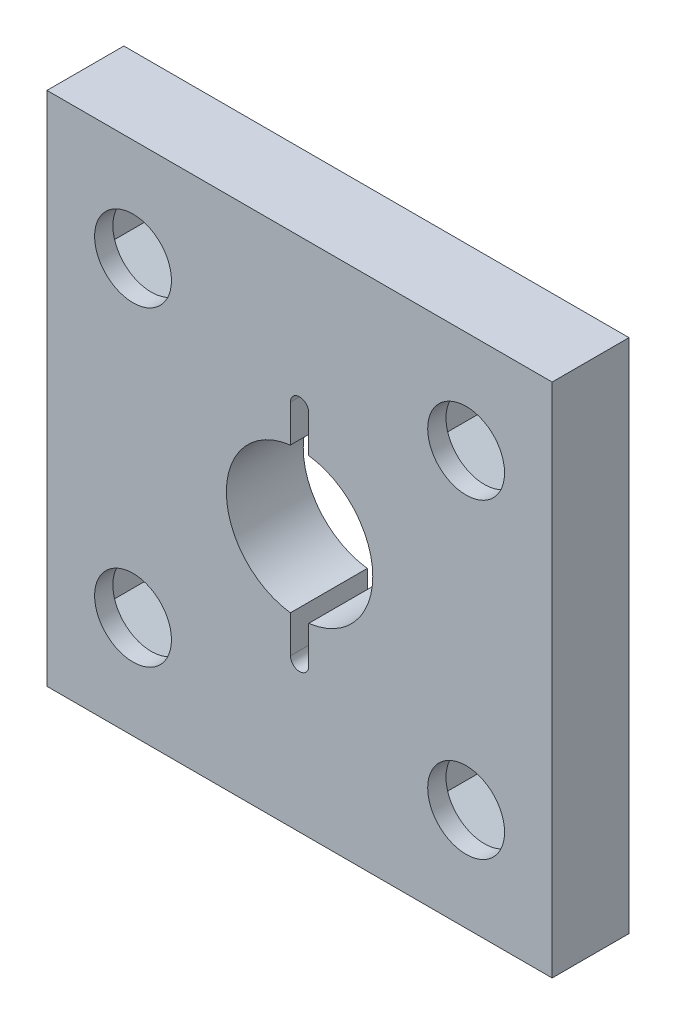
from build123d import *

# Parameters (mm, degrees)
SKETCH1_W           = 35.052
SKETCH1_H           = 35.814
SKETCH1_R           = 2.667
BOSS_EXTRUDE1_DEPTH = 5.334
CUT_EXTRUDE1_DEPTH  = 4.064
SKETCH3_R           = 5.08
CUT_EXTRUDE2_DEPTH  = 6.334
CUT_EXTRUDE3_DEPTH  = 6.334


with BuildPart() as part:
    # Sketch1 → Boss-Extrude1 (new body)
    with BuildSketch(Plane.XY):
        Rectangle(SKETCH1_W, SKETCH1_H)
        with Locations((-11.557, 10.795)):
            Circle(SKETCH1_R, mode=Mode.SUBTRACT)
        with Locations((11.557, 10.795)):
            Circle(SKETCH1_R, mode=Mode.SUBTRACT)
        with Locations((11.557, -10.795)):
            Circle(SKETCH1_R, mode=Mode.SUBTRACT)
        with Locations((-11.557, -10.795)):
            Circle(SKETCH1_R, mode=Mode.SUBTRACT)
    extrude(amount=BOSS_EXTRUDE1_DEPTH)

    # Sketch2 → Cut-Extrude1 (cut)
    with BuildSketch(Plane(origin=(0, 0, 0), x_dir=(-1, 0, 0), z_dir=(0, 0, -1))):
        Polygon((-11.557, 5.955650044), (-7.366, 8.375325022), (-7.366, 13.214674978), (-11.557, 15.634349956), (-15.748, 13.214674978), (-15.748, 8.375325022), align=None)
        Polygon((-11.557, -15.634349956), (-7.366, -13.214674978), (-7.366, -8.375325022), (-11.557, -5.955650044), (-15.748, -8.375325022), (-15.748, -13.214674978), align=None)
        Polygon((11.557, -15.634349956), (15.748, -13.214674978), (15.748, -8.375325022), (11.557, -5.955650044), (7.366, -8.375325022), (7.366, -13.214674978), align=None)
        Polygon((11.557, 5.955650044), (15.748, 8.375325022), (15.748, 13.214674978), (11.557, 15.634349956), (7.366, 13.214674978), (7.366, 8.375325022), align=None)
    extrude(amount=-CUT_EXTRUDE1_DEPTH, mode=Mode.SUBTRACT)

    # Sketch3 → Cut-Extrude2 (cut, through all)
    with BuildSketch(Plane.XY.offset(5.334)):
        Circle(SKETCH3_R)
    extrude(amount=-CUT_EXTRUDE2_DEPTH, mode=Mode.SUBTRACT)

    # Sketch4 → Cut-Extrude3 (cut, through all)
    with BuildSketch(Plane.XY.offset(5.334)):
        with BuildLine():
            Line((-0.635, -7.62), (-0.635, 7.62))
            ThreePointArc((-0.635, 7.62), (0, 8.255), (0.635, 7.62))
            Line((0.635, 7.62), (0.635, -7.62))
            ThreePointArc((0.635, -7.62), (0, -8.255), (-0.635, -7.62))
        make_face()
    extrude(amount=-CUT_EXTRUDE3_DEPTH, mode=Mode.SUBTRACT)


solid = part.part
